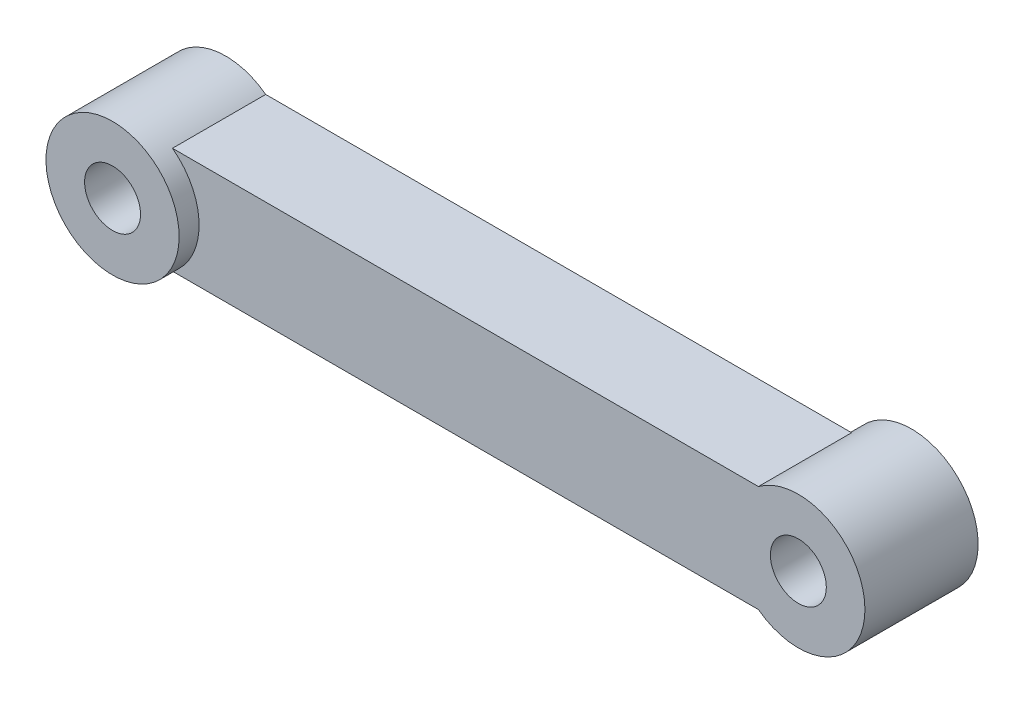
from build123d import *

# Parameters (mm, degrees)
SKETCH2_R           = 2.1
BOSS_EXTRUDE1_DEPTH = 7
SKETCH3_R           = 5
SKETCH3_R_2         = 2.1
BOSS_EXTRUDE2_DEPTH = 1.5
SKETCH4_R           = 5
SKETCH4_R_2         = 2.1
BOSS_EXTRUDE3_DEPTH = 1.5


with BuildPart() as part:
    # Sketch2 → Boss-Extrude1 (new body)
    with BuildSketch(Plane.XY):
        with BuildLine():
            ThreePointArc((-40.021658011, 2.236067977), (-48.021658011, -1.763932023), (-40.021658011, -5.763932023))
            Line((-40.021658011, -5.763932023), (-40.021658011, 2.236067977))
        make_face()
        with Locations((-43.021658011, -1.763932023)):
            Circle(SKETCH2_R, mode=Mode.SUBTRACT)
        with BuildLine():
            Line((-40.021658011, 2.236067977), (-40.021658011, -5.763932023))
            ThreePointArc((-40.021658011, -5.763932023), (-38.549522056, -4), (-38.021658011, -1.763932023))
            ThreePointArc((-38.021658011, -1.763932023), (-38.549522056, 0.472135955), (-40.021658011, 2.236067977))
        make_face()
        with BuildLine():
            ThreePointArc((-38.021658011, -1.763932023), (-38.549522056, -4), (-40.021658011, -5.763932023))
            Line((-40.021658011, -5.763932023), (3.978341989, -5.763932023))
            ThreePointArc((3.978341989, -5.763932023), (1.978341989, -1.763932023), (3.978341989, 2.236067977))
            Line((3.978341989, 2.236067977), (-40.021658011, 2.236067977))
            ThreePointArc((-40.021658011, 2.236067977), (-38.549522056, 0.472135955), (-38.021658011, -1.763932023))
        make_face()
        with BuildLine():
            Line((3.978341989, 2.236067977), (3.978341989, -5.763932023))
            ThreePointArc((3.978341989, -5.763932023), (9.214409967, -6.236067977), (11.978341989, -1.763932023))
            ThreePointArc((11.978341989, -1.763932023), (9.214409967, 2.708203932), (3.978341989, 2.236067977))
        make_face()
        with Locations((6.978341989, -1.763932023)):
            Circle(SKETCH2_R, mode=Mode.SUBTRACT)
        with BuildLine():
            ThreePointArc((3.978341989, 2.236067977), (1.978341989, -1.763932023), (3.978341989, -5.763932023))
            Line((3.978341989, -5.763932023), (3.978341989, 2.236067977))
        make_face()
    extrude(amount=BOSS_EXTRUDE1_DEPTH)

    # Sketch3 → Boss-Extrude2 (add)
    with BuildSketch(Plane.XY.offset(7)):
        with Locations((-43.021658011, -1.763932023)):
            Circle(SKETCH3_R)
        with Locations((-43.021658011, -1.763932023)):
            Circle(SKETCH3_R_2, mode=Mode.SUBTRACT)
    extrude(amount=BOSS_EXTRUDE2_DEPTH)

    # Sketch4 → Boss-Extrude3 (add)
    with BuildSketch(Plane(origin=(0, 0, 0), x_dir=(-1, 0, 0), z_dir=(0, 0, -1))):
        with Locations((-6.978341989, -1.763932023)):
            Circle(SKETCH4_R)
        with Locations((-6.978341989, -1.763932023)):
            Circle(SKETCH4_R_2, mode=Mode.SUBTRACT)
    extrude(amount=BOSS_EXTRUDE3_DEPTH)


solid = part.part
